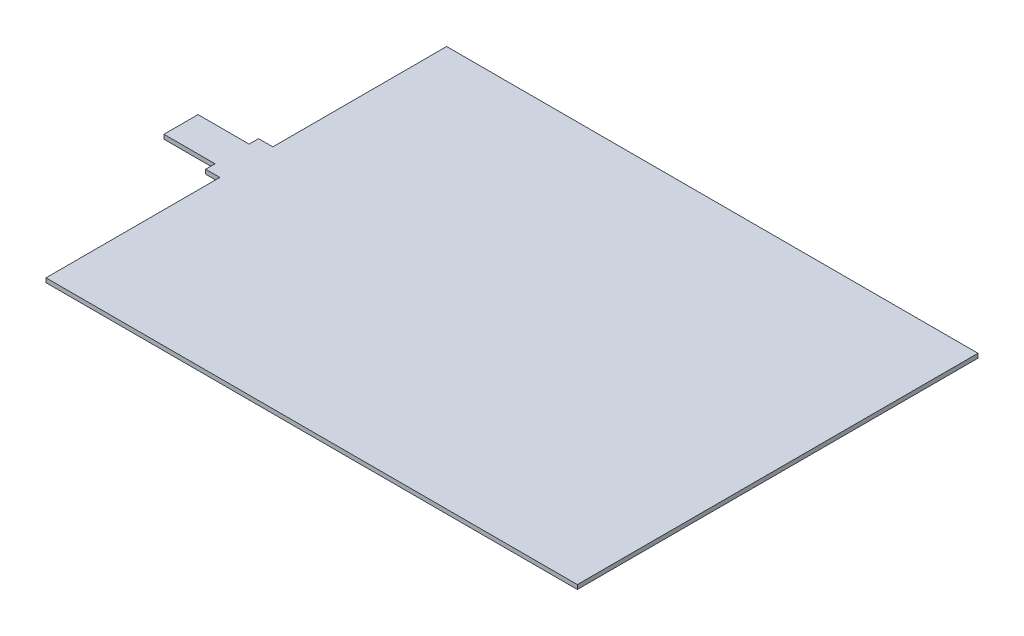
from build123d import *

# Parameters (mm, degrees)
BOSS_EXTRUDE1_DEPTH = 1.5
SKETCH2_W           = 18
SKETCH2_H           = 12
BOSS_EXTRUDE2_DEPTH = 1.5


with BuildPart() as part:
    # Sketch1 → Boss-Extrude1 (new body)
    with BuildSketch(Plane(origin=(0, 0, 0), x_dir=(1, 0, 0), z_dir=(0, 1, 0))):
        Polygon((-93.5, 9.325), (-93.5, 70.5), (93.5, 70.5), (93.5, -70.5), (-93.5, -70.5), (-93.5, -9.325), (-98.5, -9.325), (-98.5, 9.325), align=None)
    extrude(amount=BOSS_EXTRUDE1_DEPTH)

    # Sketch2 → Boss-Extrude2 (add)
    with BuildSketch(Plane(origin=(0, 1.5, 0), x_dir=(1, 0, 0), z_dir=(0, 1, 0))):
        with Locations((-107.5, 0)):
            Rectangle(SKETCH2_W, SKETCH2_H)
    extrude(amount=-BOSS_EXTRUDE2_DEPTH)


solid = part.part
